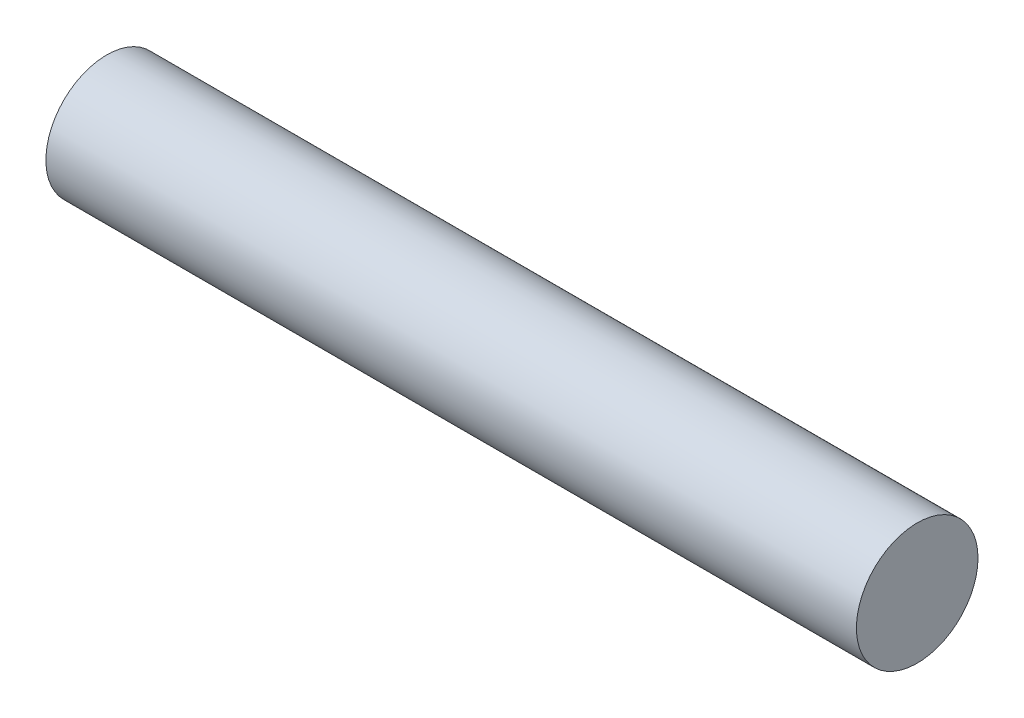
from build123d import *

# Parameters (mm, degrees)
SKETCH1_R           = 9.525
BOSS_EXTRUDE1_DEPTH = 127


with BuildPart() as part:
    # Sketch1 → Boss-Extrude1 (new body)
    with BuildSketch(Plane(origin=(0, 0, 0), x_dir=(0, 0, -1), z_dir=(1, 0, 0))):
        Circle(SKETCH1_R)
    extrude(amount=BOSS_EXTRUDE1_DEPTH)


solid = part.part
